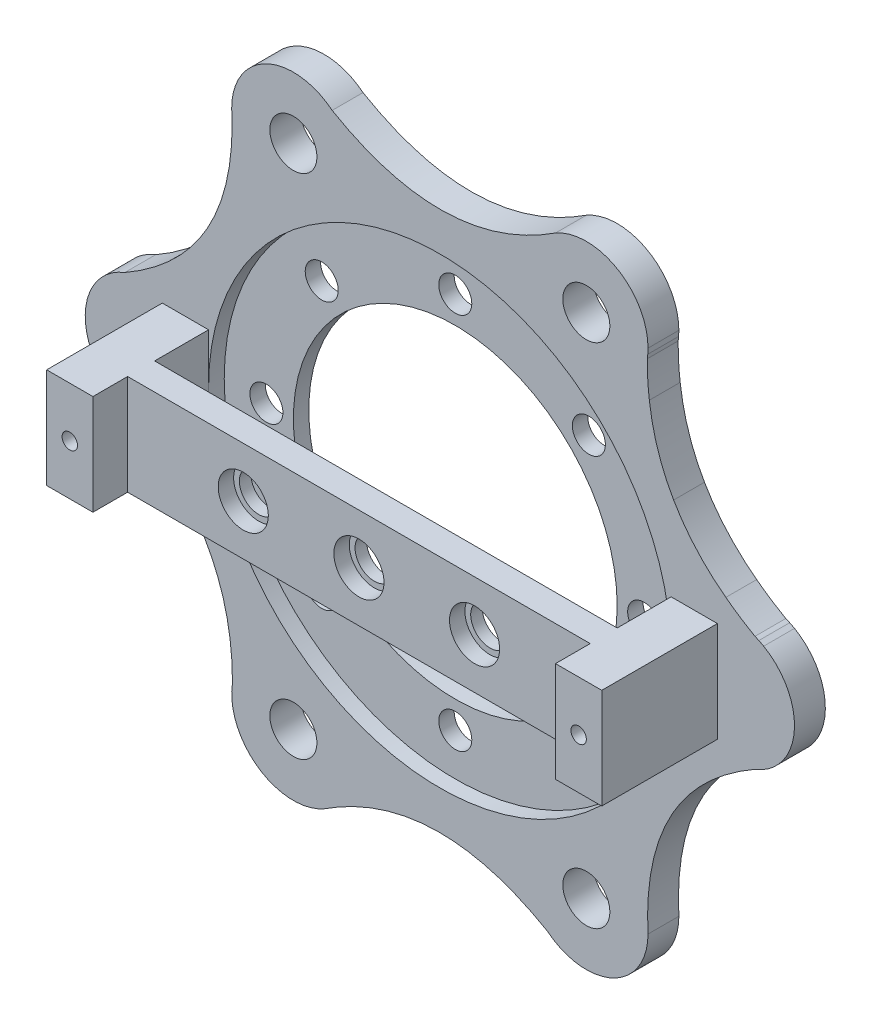
from build123d import *

# Parameters (mm, degrees)
SKETCH1_R           = 3.05
SKETCH1_R_2         = 30
BOSS_EXTRUDE1_DEPTH = 4
SKETCH2_W           = 6
SKETCH2_H           = 13
BOSS_EXTRUDE3_DEPTH = 15
SKETCH3_W           = 3.5
SKETCH3_H           = 13
BOSS_EXTRUDE4_DEPTH = 60
SKETCH4_R           = 2.5
CUT_EXTRUDE2_DEPTH  = 15.5000001
SKETCH5_R           = 3.25
CUT_EXTRUDE3_DEPTH  = 2
BOSS_EXTRUDE6_START = -2
SKETCH6_R           = 29.970088814
SKETCH6_R_2         = 21
BOSS_EXTRUDE6_DEPTH = 2
SKETCH7_R           = 2.141207247
CUT_EXTRUDE4_DEPTH  = 2
SKETCH9_R           = 1
CUT_EXTRUDE5_DEPTH  = 9


with BuildPart() as part:
    # Sketch1 → Boss-Extrude1 (new body)
    with BuildSketch(Plane.XY):
        with BuildLine():
            add(Edge.make_bspline(
                [(41.831083973, -7.3304071), (27.361930458, -15.606097707), (27.931076287, -32.06813474)],
                knots=[0, 0, 0, 0.979190426, 0.979190426, 0.979190426], degree=2))
            ThreePointArc((41.831083973, -7.3304071), (46.937485003, -0.489124386), (42.962058943, 7.065640222))
            add(Edge.make_bspline(
                [(42.337410878, 7.390505261), (42.646435969, 7.226056086), (42.962058943, 7.065640222)],
                knots=[0.979190426, 0.979190426, 0.979190426, 1, 1, 1], degree=2))
            ThreePointArc((42.337410878, 7.390505261), (42.086093687, 7.502245674), (41.831083973, 7.605281084))
            add(Edge.make_bspline(
                [(41.831083973, 7.605281084), (39.79510994, 8.769764629), (38.056889456, 10.096335232)],
                knots=[0, 0, 0, 0.137783201, 0.137783201, 0.137783201], degree=2))
            add(Edge.make_bspline(
                [(31.283656242, 17.643619355), (33.76797305, 13.318397895), (38.056889456, 10.096335232)],
                knots=[0.478313075, 0.478313075, 0.478313075, 0.822465871, 0.822465871, 0.822465871], degree=2))
            add(Edge.make_bspline(
                [(31.283656242, 17.643619355), (28.780062988, 21.957711547), (28.13413307, 27.283053433)],
                knots=[0.478313075, 0.478313075, 0.478313075, 0.82246587, 0.82246587, 0.82246587], degree=2))
            add(Edge.make_bspline(
                [(27.863914153, 31.79712885), (27.854399469, 29.451681837), (28.13413307, 27.283053433)],
                knots=[0, 0, 0, 0.137783201, 0.137783201, 0.137783201], degree=2))
            ThreePointArc((27.863914153, 31.79712885), (27.902187728, 32.069491448), (27.931076287, 32.343008727))
            add(Edge.make_bspline(
                [(27.931076287, 32.343008727), (27.943171669, 32.692856892), (27.962058943, 33.046402336)],
                knots=[0.979190426, 0.979190426, 0.979190426, 1, 1, 1], degree=2))
            ThreePointArc((27.962058943, 33.046402336), (23.962058943, 39.974605566), (15.962058943, 39.974605566))
            add(Edge.make_bspline(
                [(15.368393534, 39.596076993), (15.665323243, 39.781475984), (15.962058943, 39.974605566)],
                knots=[0.979190426, 0.979190426, 0.979190426, 1, 1, 1], degree=2))
            add(Edge.make_bspline(
                [(-13.005110877, 39.264972942), (1.39642418, 30.87216373), (15.368393534, 39.596076993)],
                knots=[0, 0, 0, 0.979190426, 0.979190426, 0.979190426], degree=2))
            ThreePointArc((-13.005110877, 39.264972942), (-21.483036017, 40.266604599), (-26.037941057, 33.046402336))
            add(Edge.make_bspline(
                [(-26.006958401, 32.343008724), (-26.019053783, 32.69285689), (-26.037941057, 33.046402336)],
                knots=[0.979190426, 0.979190426, 0.979190426, 1, 1, 1], degree=2))
            add(Edge.make_bspline(
                [(-39.906966087, 7.605281083), (-25.437812572, 15.880971691), (-26.006958401, 32.343008724)],
                knots=[0, 0, 0, 0.979190426, 0.979190426, 0.979190426], degree=2))
            ThreePointArc((-39.906966087, 7.605281083), (-45.013367117, 0.76399837), (-41.037941057, -6.790766239))
            add(Edge.make_bspline(
                [(-40.413292992, -7.115631277), (-40.722318083, -6.951182102), (-41.037941057, -6.790766238)],
                knots=[0.979190426, 0.979190426, 0.979190426, 1, 1, 1], degree=2))
            add(Edge.make_bspline(
                [(-25.939796267, -31.522254866), (-25.872177809, -14.853755047), (-40.413292992, -7.115631277)],
                knots=[0, 0, 0, 0.979190426, 0.979190426, 0.979190426], degree=2))
            ThreePointArc((-25.939796267, -31.522254866), (-22.568272157, -39.365169237), (-14.037941057, -39.699731582))
            add(Edge.make_bspline(
                [(-13.444275648, -39.321203009), (-13.741205357, -39.506602), (-14.037941057, -39.699731582)],
                knots=[0.979190426, 0.979190426, 0.979190426, 1, 1, 1], degree=2))
            add(Edge.make_bspline(
                [(14.929228763, -38.990098958), (0.527693706, -30.597289746), (-13.444275648, -39.321203009)],
                knots=[0, 0, 0, 0.979190426, 0.979190426, 0.979190426], degree=2))
            ThreePointArc((14.929228763, -38.990098958), (23.407153903, -39.991730615), (27.962058943, -32.771528352))
            add(Edge.make_bspline(
                [(27.931076287, -32.06813474), (27.943171669, -32.417982907), (27.962058943, -32.771528352)],
                knots=[0.979190426, 0.979190426, 0.979190426, 1, 1, 1], degree=2))
        make_face()
        with Locations((-18.037941057, -32.771528352)):
            Circle(SKETCH1_R, mode=Mode.SUBTRACT)
        with Locations((0.962058943, 0.137436992)):
            Circle(SKETCH1_R_2, mode=Mode.SUBTRACT)
        with Locations((19.962058943, -32.771528352)):
            Circle(SKETCH1_R, mode=Mode.SUBTRACT)
        with Locations((-37.037941057, 0.137436992)):
            Circle(SKETCH1_R, mode=Mode.SUBTRACT)
        with Locations((-18.037941057, 33.046402336)):
            Circle(SKETCH1_R, mode=Mode.SUBTRACT)
        with Locations((38.962058943, 0.137436992)):
            Circle(SKETCH1_R, mode=Mode.SUBTRACT)
        with Locations((19.962058943, 33.046402336)):
            Circle(SKETCH1_R, mode=Mode.SUBTRACT)
        with Locations((-37.037941057, 0.137436992)):
            Circle(SKETCH1_R)
        with Locations((38.962058943, 0.137436992)):
            Circle(SKETCH1_R)
    extrude(amount=BOSS_EXTRUDE1_DEPTH)

    # Sketch2 → Boss-Extrude3 (add)
    with BuildSketch(Plane.XY.offset(4)):
        with Locations((-32.037941057, 0.107525805)):
            Rectangle(SKETCH2_W, SKETCH2_H)
        with Locations((33.962058943, 0.107525805)):
            Rectangle(SKETCH2_W, SKETCH2_H)
    extrude(amount=BOSS_EXTRUDE3_DEPTH)

    # Sketch3 → Boss-Extrude4 (add)
    with BuildSketch(Plane.ZY.offset(-30.962058943)):
        with Locations((12.75, 0.107525805)):
            Rectangle(SKETCH3_W, SKETCH3_H)
    extrude(amount=BOSS_EXTRUDE4_DEPTH)

    # Sketch4 → Cut-Extrude2 (cut, through all)
    with BuildSketch(Plane.XY.offset(14.5)):
        with Locations((-14.037941057, 0.107525805)):
            Circle(SKETCH4_R)
        with Locations((0.962058943, 0.107525805)):
            Circle(SKETCH4_R)
        with Locations((15.962058943, 0.107525805)):
            Circle(SKETCH4_R)
    extrude(amount=-CUT_EXTRUDE2_DEPTH, mode=Mode.SUBTRACT)

    # Sketch5 → Cut-Extrude3 (cut)
    with BuildSketch(Plane.XY.offset(14.5)):
        with Locations((-14.037941057, 0.107525805)):
            Circle(SKETCH5_R)
        with Locations((0.962058943, 0.107525805)):
            Circle(SKETCH5_R)
        with Locations((15.962058943, 0.107525805)):
            Circle(SKETCH5_R)
    extrude(amount=-CUT_EXTRUDE3_DEPTH, mode=Mode.SUBTRACT)

    # Sketch9 → Cut-Extrude5 (cut)
    with BuildSketch(Plane.XY.offset(19)):
        with Locations((33.962058943, 0.107525805)):
            Circle(SKETCH9_R)
        with Locations((-32.037941057, 0.107525805)):
            Circle(SKETCH9_R)
    extrude(amount=-CUT_EXTRUDE5_DEPTH, mode=Mode.SUBTRACT)


with BuildPart() as body_2:
    # Sketch6 → Boss-Extrude6 (new body)
    with BuildSketch(Plane.XY.offset(4).offset(BOSS_EXTRUDE6_START)):
        with Locations((0.962058943, 0.107525805)):
            Circle(SKETCH6_R)
        with Locations((0.962058943, 0.107525805)):
            Circle(SKETCH6_R_2, mode=Mode.SUBTRACT)
    extrude(amount=-BOSS_EXTRUDE6_DEPTH)

    # Sketch7 → Cut-Extrude4 (cut)
    with BuildSketch(Plane(origin=(0, 0, 0), x_dir=(-1, 0, 0), z_dir=(0, 0, -1))):
        with Locations((-0.962058943, 24.607525805)):
            Circle(SKETCH7_R)
        with Locations((16.362057196, 17.431641944)):
            Circle(SKETCH7_R)
        with Locations((23.537941057, 0.107525805)):
            Circle(SKETCH7_R)
        with Locations((16.362057196, -17.216590334)):
            Circle(SKETCH7_R)
        with Locations((-0.962058943, -24.392474195)):
            Circle(SKETCH7_R)
        with Locations((-18.286175082, -17.216590334)):
            Circle(SKETCH7_R)
        with Locations((-25.462058943, 0.107525805)):
            Circle(SKETCH7_R)
        with Locations((-18.286175082, 17.431641944)):
            Circle(SKETCH7_R)
    extrude(amount=-CUT_EXTRUDE4_DEPTH, mode=Mode.SUBTRACT)


solid = Compound([part.part, body_2.part])
